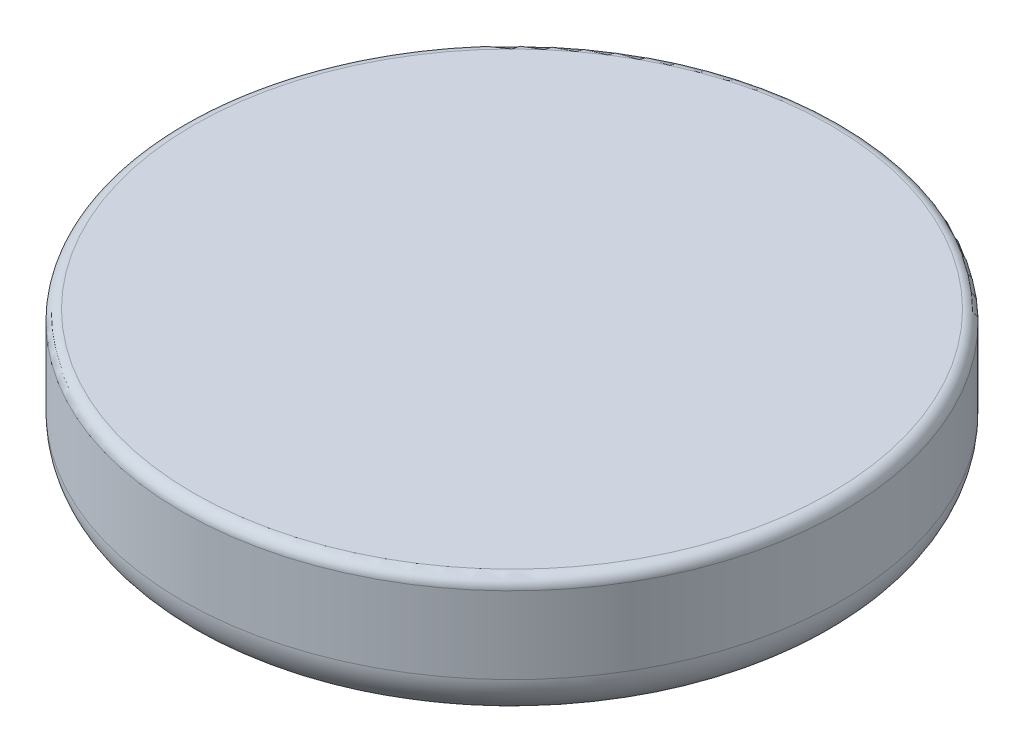
from build123d import *

# Parameters (mm, degrees)
SKETCH1_R           = 7.5
BOSS_EXTRUDE1_DEPTH = 3
FILLET1_R           = 1
SKETCH2_W           = 1.4
SKETCH2_H           = 5.1
CUT_EXTRUDE1_DEPTH  = 2
FILLET2_R           = 0.25


with BuildPart() as part:
    # Sketch1 → Boss-Extrude1 (new body)
    with BuildSketch(Plane(origin=(0, 0, 0), x_dir=(1, 0, 0), z_dir=(0, 1, 0))):
        with Locations(Location((0, 0, 0), (0, 0, 270))):  # turned: the seam where the file's is
            Circle(SKETCH1_R)
    extrude(amount=BOSS_EXTRUDE1_DEPTH)

    # Fillet1
    fillet1_edges = [part.edges().sort_by_distance(p)[0] for p in [
        (0, 0, -7.5),
    ]]
    fillet(fillet1_edges, radius=FILLET1_R)

    # Sketch2 → Cut-Extrude1 (cut)
    with BuildSketch(Plane.XZ):
        Rectangle(SKETCH2_W, SKETCH2_H)
    extrude(amount=-CUT_EXTRUDE1_DEPTH, mode=Mode.SUBTRACT)

    # Fillet2
    fillet2_edges = [part.edges().sort_by_distance(p)[0] for p in [
        (-0.7, 0, 0),
        (0.7, 0, 0),
        (0, 3, -7.5),
    ]]
    fillet(fillet2_edges, radius=FILLET2_R)


solid = part.part
